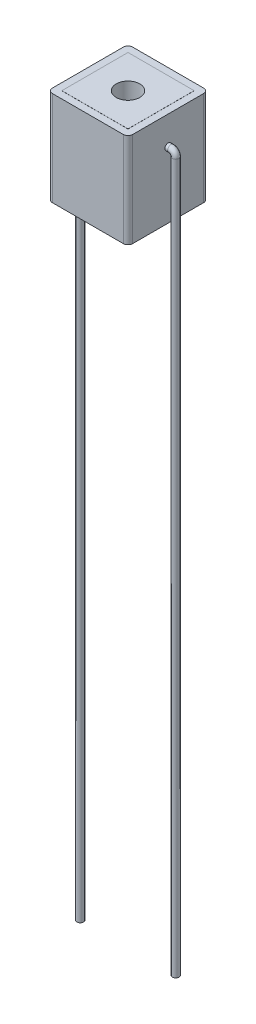
from build123d import *

# Parameters (mm, degrees)
SKETCH1_W                = 8.5
SKETCH1_H                = 8.5
BOSS_EXTRUDE1_DEPTH      = 10
SKETCH2_W                = 7
SKETCH2_H                = 7
BOSS_EXTRUDE2_DEPTH      = 10.01
BOSS_EXTRUDE2_DEPTH_BACK = 0.01
FILLET2_R                = 0.5
SKETCH35_R               = 1.25
CUT_EXTRUDE1_DEPTH       = 20
SWEEP1_PROFILE_R         = 0.35


with BuildPart() as part:
    # Sketch1 → Boss-Extrude1 (new body)
    with BuildSketch(Plane(origin=(0, 0, 0), x_dir=(1, 0, 0), z_dir=(0, 1, 0))):
        Rectangle(SKETCH1_W, SKETCH1_H)
    extrude(amount=BOSS_EXTRUDE1_DEPTH)

    # Sketch2 → Boss-Extrude2 (add, two sides)
    with BuildSketch(Plane(origin=(0, 0, 0), x_dir=(1, 0, 0), z_dir=(0, 1, 0))) as boss_extrude2_sk:
        Rectangle(SKETCH2_W, SKETCH2_H)
    extrude(amount=BOSS_EXTRUDE2_DEPTH)
    extrude(boss_extrude2_sk.sketch, amount=-BOSS_EXTRUDE2_DEPTH_BACK)

    # Fillet2
    fillet2_edges = [part.edges().sort_by_distance(p)[0] for p in [
        (4.25, 5, 4.25),
        (-4.25, 5, 4.25),
        (-4.25, 5, -4.25),
        (4.25, 5, -4.25),
    ]]
    fillet(fillet2_edges, radius=FILLET2_R)

    # Sketch35 → Cut-Extrude1 (cut)
    with BuildSketch(Plane(origin=(0, 10.01, 0), x_dir=(1, 0, 0), z_dir=(0, 1, 0))):
        with Locations(Location((0, 0, 0), (0, 0, 270))):  # turned: the seam where the file's is
            Circle(SKETCH35_R)
    extrude(amount=-CUT_EXTRUDE1_DEPTH, mode=Mode.SUBTRACT)

    # Sweep1: sweep along a path in Sketch37
    with BuildLine(Plane.XY) as sweep1_path:
        Line((4.25, 7), (4.55, 7))
        ThreePointArc((4.55, 7), (4.903553391, 6.853553391), (5.05, 6.5))
        Line((5.05, 6.5), (5.05, -68.5))
    # Sweep1 profile (on start of the path) → Sweep1 (sweep)
    with BuildSketch(Plane(origin=(4.25, 7, 0), x_dir=(0, 0, 1), z_dir=(1, 0, 0))):
        Circle(SWEEP1_PROFILE_R)
    sweep1 = sweep(path=sweep1_path.line)

    # Mirror1: Sweep1 across plane
    add(sweep1.mirror(Plane(origin=(0, 0, 0), x_dir=(0, 0, 1), z_dir=(1, 0, 0))))


solid = part.part
